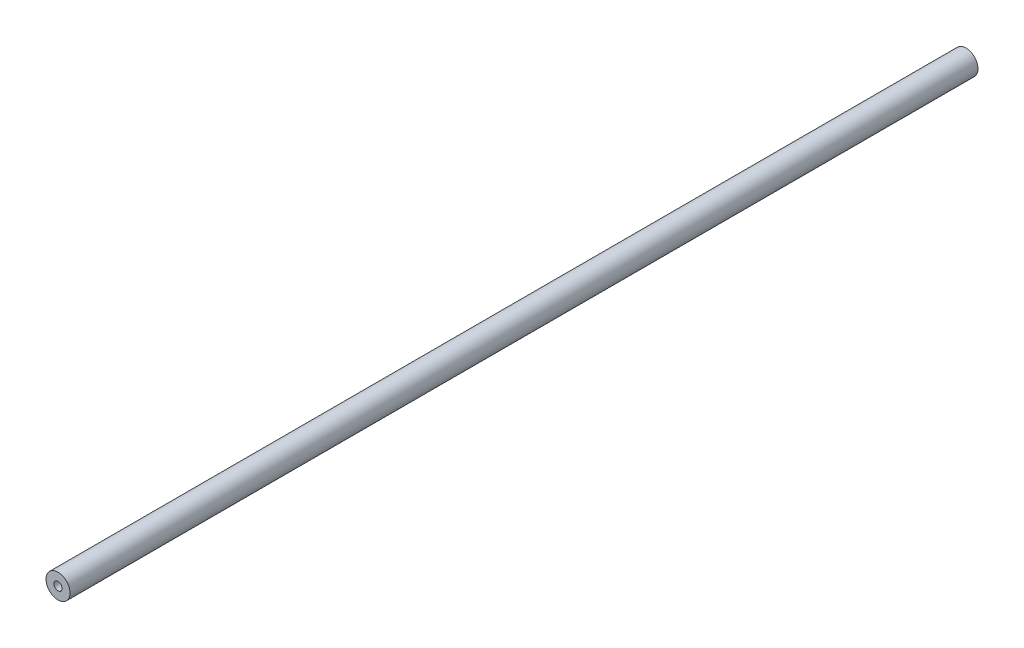
from build123d import *

# Parameters (mm, degrees)
SKETCH_1_R             = 12.5
EXTRUDE_1_DEPTH        = 10
EXTRUDE_1_DEPTH_BACK   = 461.6
HOLE_WIZARD_M101_D     = 8.5
HOLE_WIZARD_M101_DEPTH = 27.5
HOLE_WIZARD_M101_TIP   = 2.553657631


with BuildPart() as part:
    # Эскиз1 → Бобышка-Вытянуть1 (new body, two sides)
    with BuildSketch(Plane.XY) as extrude_1_sk:
        Circle(SKETCH_1_R)
    extrude(amount=EXTRUDE_1_DEPTH)
    extrude(extrude_1_sk.sketch, amount=-EXTRUDE_1_DEPTH_BACK)

    # Отверстие обработанное метчиком M101
    with Locations(Plane.XY.offset(10)):
        with Locations((0, 0)):
            Hole(HOLE_WIZARD_M101_D / 2, depth=HOLE_WIZARD_M101_DEPTH)
            with Locations((0, 0, -(HOLE_WIZARD_M101_DEPTH + HOLE_WIZARD_M101_TIP / 2))):  # 118° drill point
                Cone(0, HOLE_WIZARD_M101_D / 2, HOLE_WIZARD_M101_TIP, mode=Mode.SUBTRACT)

    # Зеркальное отражение1: part across plane


with BuildPart() as part_1:
    add(part.part)
    add(part.part.mirror(Plane(origin=(-175.346619422, 75, -461.6), x_dir=(1, 0, 0), z_dir=(0, 0, 1))))


solid = part_1.part
